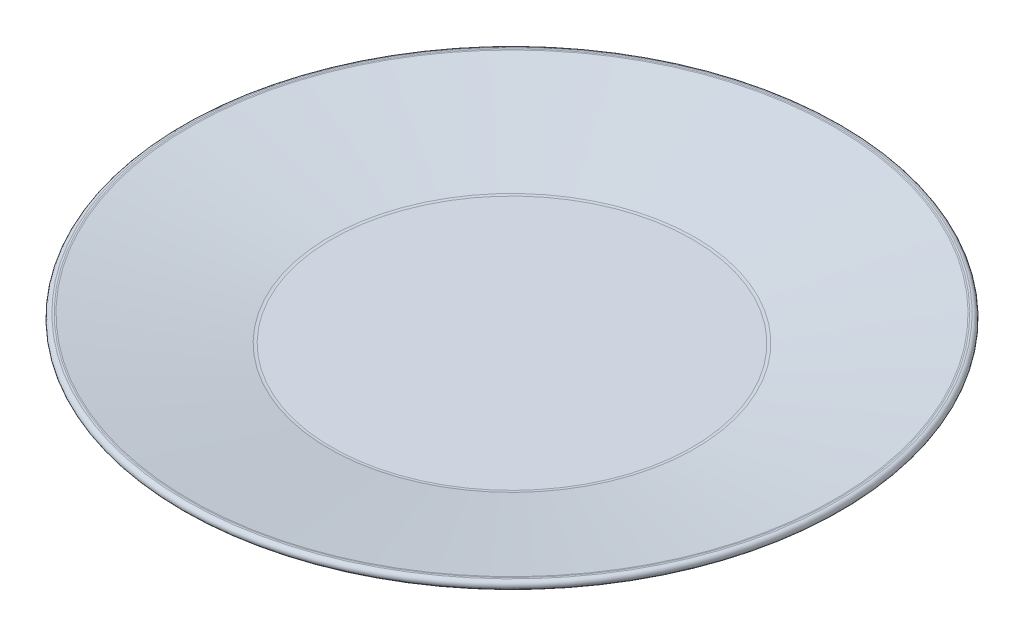
from build123d import *


with BuildPart() as part:
    # ProfileS → Profile (revolve)
    with BuildSketch(Plane.XY):
        with BuildLine():
            Line((0, 0), (51.956218422, 0))
            ThreePointArc((51.956218422, 0), (52.592060281, 0.02893802), (53.222644996, 0.11551282))
            Line((53.222644996, 0.11551282), (94.017101698, 7.619802198))
            ThreePointArc((94.017101698, 7.619802198), (94.995039197, 8.909001462), (93.8, 10))
            Line((93.8, 10), (93.320232948, 10))
            ThreePointArc((93.320232948, 10), (93.138563845, 9.991731994), (92.958396784, 9.966996337))
            Line((92.958396784, 9.966996337), (52.770349791, 2.574258241))
            ThreePointArc((52.770349791, 2.574258241), (52.364973903, 2.518603013), (51.956218422, 2.5))
            Line((51.956218422, 2.5), (0, 2.5))
            Line((0, 2.5), (0, 0))
        make_face()
    revolve(axis=Axis((0, 0, 0), (0, 1, 0)))


solid = part.part
